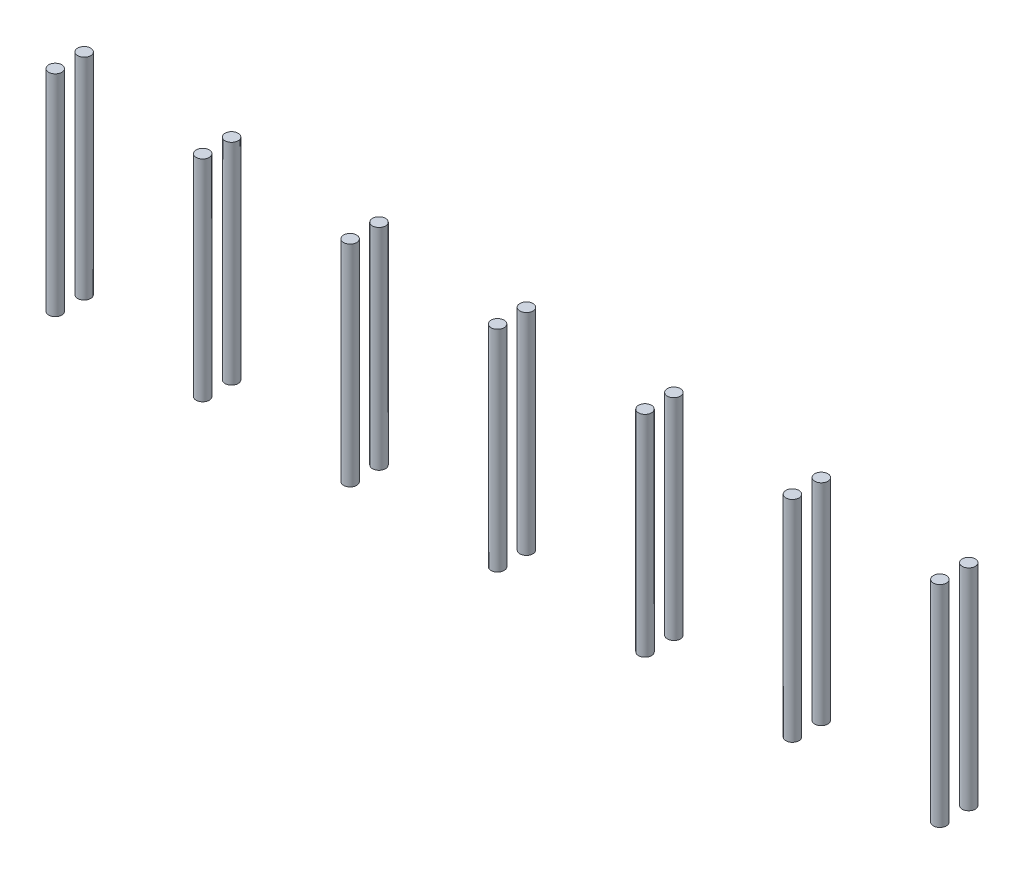
from build123d import *

# Parameters (mm, degrees)
SKETCH1_R              = 3.175
BOSS_EXTRUDE1_DEPTH    = 102
BOSS_EXTRUDE1_2_DEPTH  = 102
BOSS_EXTRUDE1_3_DEPTH  = 102
BOSS_EXTRUDE1_4_DEPTH  = 102
BOSS_EXTRUDE1_5_DEPTH  = 102
BOSS_EXTRUDE1_6_DEPTH  = 102
BOSS_EXTRUDE1_7_DEPTH  = 102
BOSS_EXTRUDE1_8_DEPTH  = 102
BOSS_EXTRUDE1_9_DEPTH  = 102
BOSS_EXTRUDE1_10_DEPTH = 102
BOSS_EXTRUDE1_11_DEPTH = 102
BOSS_EXTRUDE1_12_DEPTH = 102
BOSS_EXTRUDE1_13_DEPTH = 102
BOSS_EXTRUDE1_14_DEPTH = 102


with BuildPart() as part:
    # Sketch1 → Boss-Extrude1 (new body)
    with BuildSketch(Plane(origin=(0, -1, 0), x_dir=(1, 0, 0), z_dir=(0, 1, 0))):
        with Locations((-66.5, 42)):
            Circle(SKETCH1_R)
    extrude(amount=BOSS_EXTRUDE1_DEPTH)


with BuildPart() as body_2:
    # Sketch1 → Boss-Extrude1 2 (new body)
    with BuildSketch(Plane(origin=(0, -1, 0), x_dir=(1, 0, 0), z_dir=(0, 1, 0))):
        with Locations((-66.5, 28)):
            Circle(SKETCH1_R)
    extrude(amount=BOSS_EXTRUDE1_2_DEPTH)


with BuildPart() as body_3:
    # Sketch1 → Boss-Extrude1 3 (new body)
    with BuildSketch(Plane(origin=(0, -1, 0), x_dir=(1, 0, 0), z_dir=(0, 1, 0))):
        with Locations((5, 42)):
            Circle(SKETCH1_R)
    extrude(amount=BOSS_EXTRUDE1_3_DEPTH)


with BuildPart() as body_4:
    # Sketch1 → Boss-Extrude1 4 (new body)
    with BuildSketch(Plane(origin=(0, -1, 0), x_dir=(1, 0, 0), z_dir=(0, 1, 0))):
        with Locations((5, 28)):
            Circle(SKETCH1_R)
    extrude(amount=BOSS_EXTRUDE1_4_DEPTH)


with BuildPart() as body_5:
    # Sketch1 → Boss-Extrude1 5 (new body)
    with BuildSketch(Plane(origin=(0, -1, 0), x_dir=(1, 0, 0), z_dir=(0, 1, 0))):
        with Locations((76.5, 42)):
            Circle(SKETCH1_R)
    extrude(amount=BOSS_EXTRUDE1_5_DEPTH)


with BuildPart() as body_6:
    # Sketch1 → Boss-Extrude1 6 (new body)
    with BuildSketch(Plane(origin=(0, -1, 0), x_dir=(1, 0, 0), z_dir=(0, 1, 0))):
        with Locations((76.5, 28)):
            Circle(SKETCH1_R)
    extrude(amount=BOSS_EXTRUDE1_6_DEPTH)


with BuildPart() as body_7:
    # Sketch1 → Boss-Extrude1 7 (new body)
    with BuildSketch(Plane(origin=(0, -1, 0), x_dir=(1, 0, 0), z_dir=(0, 1, 0))):
        with Locations((148, 42)):
            Circle(SKETCH1_R)
    extrude(amount=BOSS_EXTRUDE1_7_DEPTH)


with BuildPart() as body_8:
    # Sketch1 → Boss-Extrude1 8 (new body)
    with BuildSketch(Plane(origin=(0, -1, 0), x_dir=(1, 0, 0), z_dir=(0, 1, 0))):
        with Locations((148, 28)):
            Circle(SKETCH1_R)
    extrude(amount=BOSS_EXTRUDE1_8_DEPTH)


with BuildPart() as body_9:
    # Sketch1 → Boss-Extrude1 9 (new body)
    with BuildSketch(Plane(origin=(0, -1, 0), x_dir=(1, 0, 0), z_dir=(0, 1, 0))):
        with Locations((219.5, 42)):
            Circle(SKETCH1_R)
    extrude(amount=BOSS_EXTRUDE1_9_DEPTH)


with BuildPart() as body_10:
    # Sketch1 → Boss-Extrude1 10 (new body)
    with BuildSketch(Plane(origin=(0, -1, 0), x_dir=(1, 0, 0), z_dir=(0, 1, 0))):
        with Locations((219.5, 28)):
            Circle(SKETCH1_R)
    extrude(amount=BOSS_EXTRUDE1_10_DEPTH)


with BuildPart() as body_11:
    # Sketch1 → Boss-Extrude1 11 (new body)
    with BuildSketch(Plane(origin=(0, -1, 0), x_dir=(1, 0, 0), z_dir=(0, 1, 0))):
        with Locations((291, 42)):
            Circle(SKETCH1_R)
    extrude(amount=BOSS_EXTRUDE1_11_DEPTH)


with BuildPart() as body_12:
    # Sketch1 → Boss-Extrude1 12 (new body)
    with BuildSketch(Plane(origin=(0, -1, 0), x_dir=(1, 0, 0), z_dir=(0, 1, 0))):
        with Locations((291, 28)):
            Circle(SKETCH1_R)
    extrude(amount=BOSS_EXTRUDE1_12_DEPTH)


with BuildPart() as body_13:
    # Sketch1 → Boss-Extrude1 13 (new body)
    with BuildSketch(Plane(origin=(0, -1, 0), x_dir=(1, 0, 0), z_dir=(0, 1, 0))):
        with Locations((362.5, 42)):
            Circle(SKETCH1_R)
    extrude(amount=BOSS_EXTRUDE1_13_DEPTH)


with BuildPart() as body_14:
    # Sketch1 → Boss-Extrude1 14 (new body)
    with BuildSketch(Plane(origin=(0, -1, 0), x_dir=(1, 0, 0), z_dir=(0, 1, 0))):
        with Locations((362.5, 28)):
            Circle(SKETCH1_R)
    extrude(amount=BOSS_EXTRUDE1_14_DEPTH)


solid = Compound([part.part, body_2.part, body_3.part, body_4.part, body_5.part, body_6.part, body_7.part, body_8.part, body_9.part, body_10.part, body_11.part, body_12.part, body_13.part, body_14.part])
